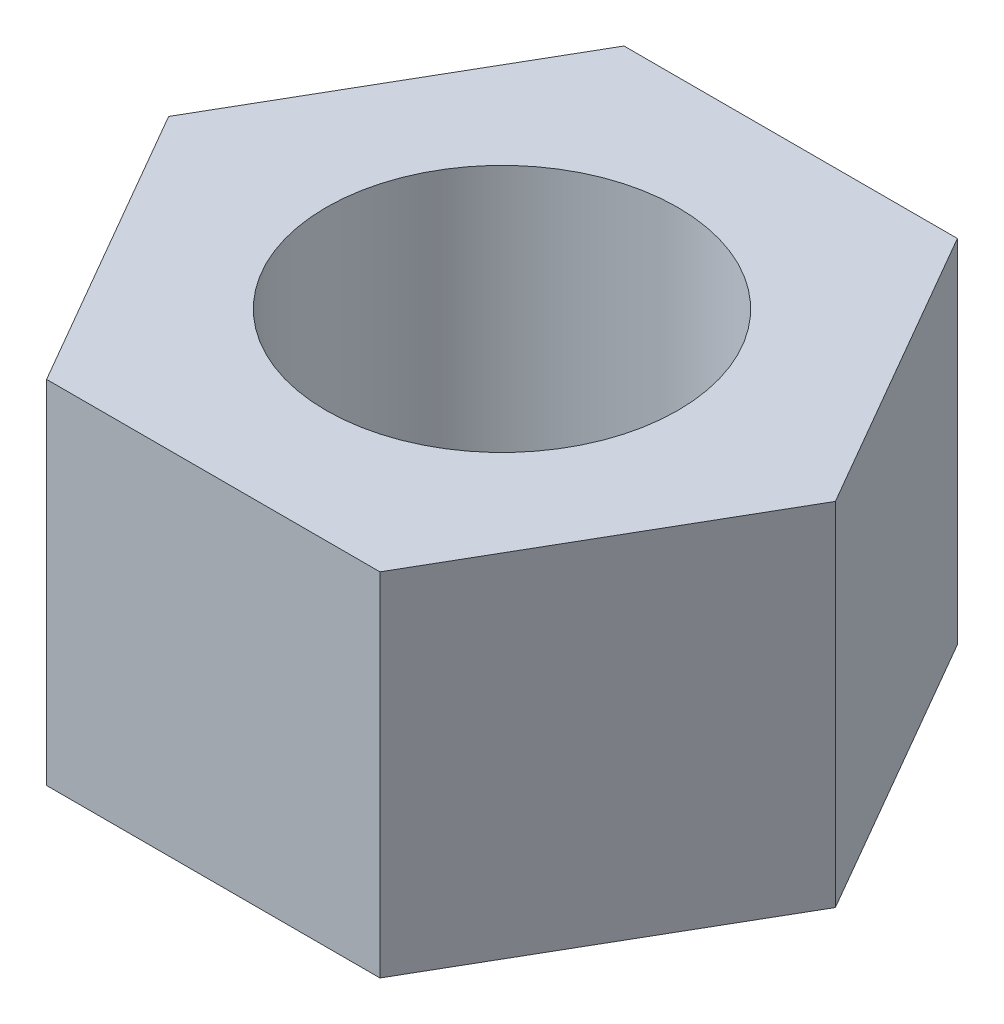
from build123d import *

# Parameters (mm, degrees)
SKETCH1_R           = 3
BOSS_EXTRUDE1_DEPTH = 6


with BuildPart() as part:
    # Sketch1 → Boss-Extrude1 (new body)
    with BuildSketch(Plane(origin=(0, 0, 0), x_dir=(1, 0, 0), z_dir=(0, 1, 0))):
        Polygon((2.843450076, 4.925), (-2.843450076, 4.925), (-5.686900152, 0), (-2.843450076, -4.925), (2.843450076, -4.925), (5.686900152, 0), align=None)
        Circle(SKETCH1_R, mode=Mode.SUBTRACT)
    extrude(amount=BOSS_EXTRUDE1_DEPTH)


solid = part.part
